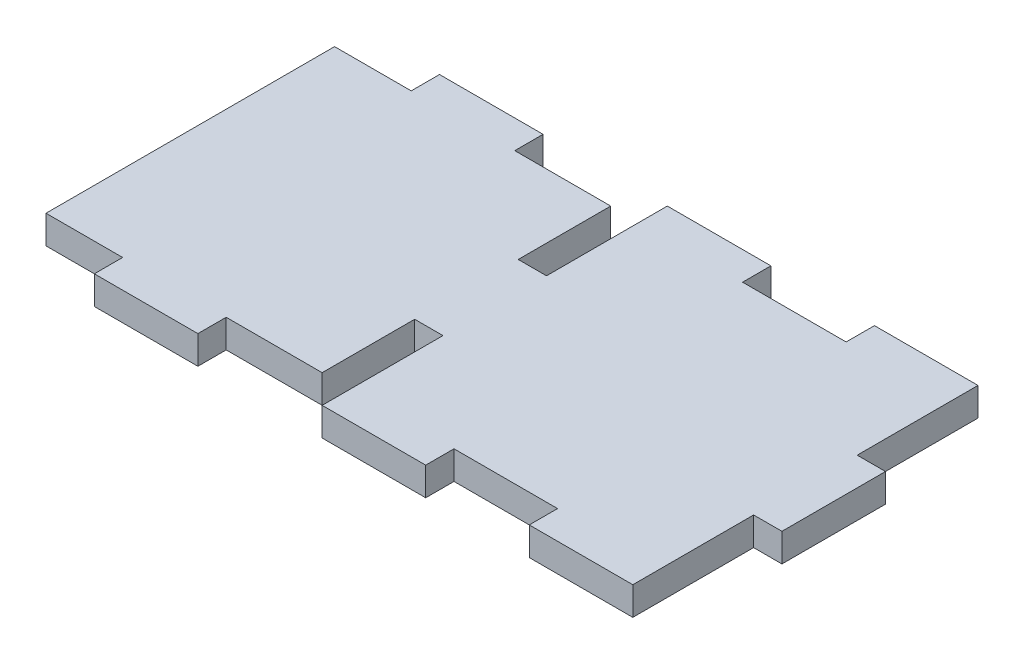
from build123d import *

# Parameters (mm, degrees)
BOSS_EXTRUDE1_DEPTH = 4.1


with BuildPart() as part:
    # Sketch1 → Boss-Extrude1 (new body)
    with BuildSketch(Plane(origin=(0, 0, 0), x_dir=(1, 0, 0), z_dir=(0, 1, 0))):
        Polygon((0, 32.5), (-4.1, 32.5), (-4.1, 45.9), (-18, 45.9), (-18, 50), (-33, 50), (-33, 45.9), (-44.1, 45.9), (-44.1, 4.1), (-33, 4.1), (-33, 0), (-18, 0), (-18, 4.1), (-4.1, 4.1), (-4.1, 17.5), (0, 17.5), (0, 0), (15, 0), (15, 4.1), (30, 4.1), (30, 0), (45, 0), (45, 17.5), (49.1, 17.5), (49.1, 32.5), (45, 32.5), (45, 50), (30, 50), (30, 45.9), (15, 45.9), (15, 50), (0, 50), align=None)
    extrude(amount=BOSS_EXTRUDE1_DEPTH)


solid = part.part
